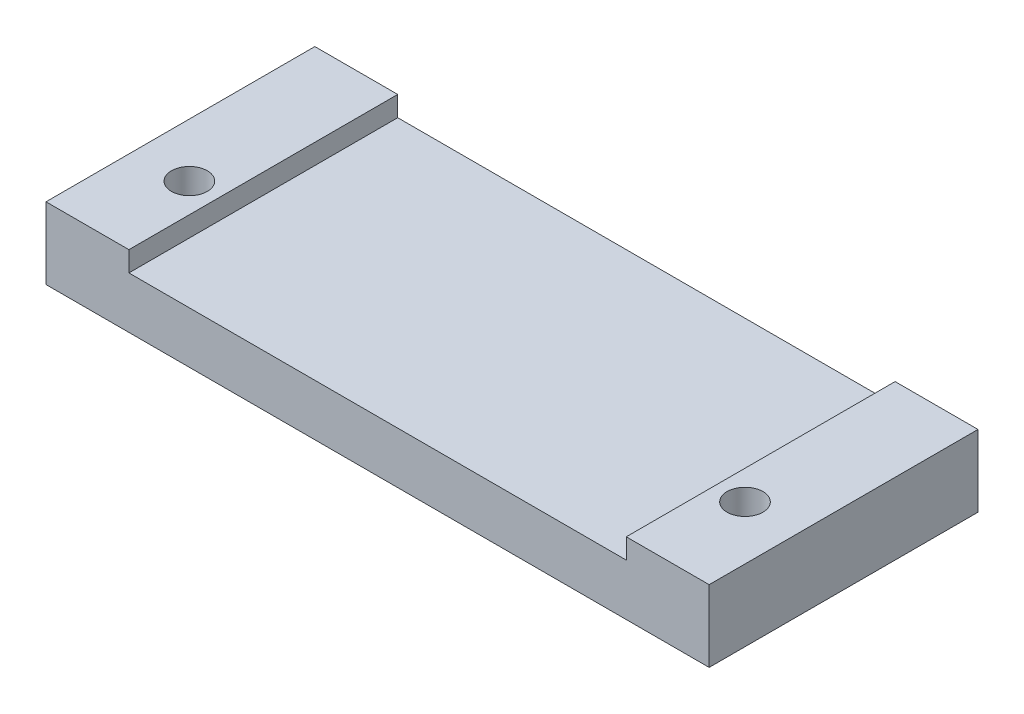
from build123d import *

# Parameters (mm, degrees)
SKETCH1_W           = 74
SKETCH1_H           = 30
BOSS_EXTRUDE1_DEPTH = 5.75
SKETCH2_W           = 9.25
SKETCH2_H           = 30
BOSS_EXTRUDE2_DEPTH = 2.25
SKETCH3_R           = 2
CUT_EXTRUDE1_DEPTH  = 9


with BuildPart() as part:
    # Sketch1 → Boss-Extrude1 (new body)
    with BuildSketch(Plane(origin=(0, 0, 0), x_dir=(1, 0, 0), z_dir=(0, 1, 0))):
        with Locations((37, 15)):
            Rectangle(SKETCH1_W, SKETCH1_H)
    extrude(amount=BOSS_EXTRUDE1_DEPTH)

    # Sketch2 → Boss-Extrude2 (add)
    with BuildSketch(Plane(origin=(0, 5.75, 0), x_dir=(1, 0, 0), z_dir=(0, 1, 0))):
        with Locations((4.625, 15)):
            Rectangle(SKETCH2_W, SKETCH2_H)
        with Locations((69.375, 15)):
            Rectangle(SKETCH2_W, SKETCH2_H)
    extrude(amount=BOSS_EXTRUDE2_DEPTH)

    # Sketch3 → Cut-Extrude1 (cut, through all)
    with BuildSketch(Plane(origin=(0, 0, 0), x_dir=(-1, 0, 0), z_dir=(0, -1, 0))):
        with Locations((-68, 10)):
            Circle(SKETCH3_R)
        with Locations((-6, 10)):
            Circle(SKETCH3_R)
    extrude(amount=-CUT_EXTRUDE1_DEPTH, mode=Mode.SUBTRACT)


solid = part.part
